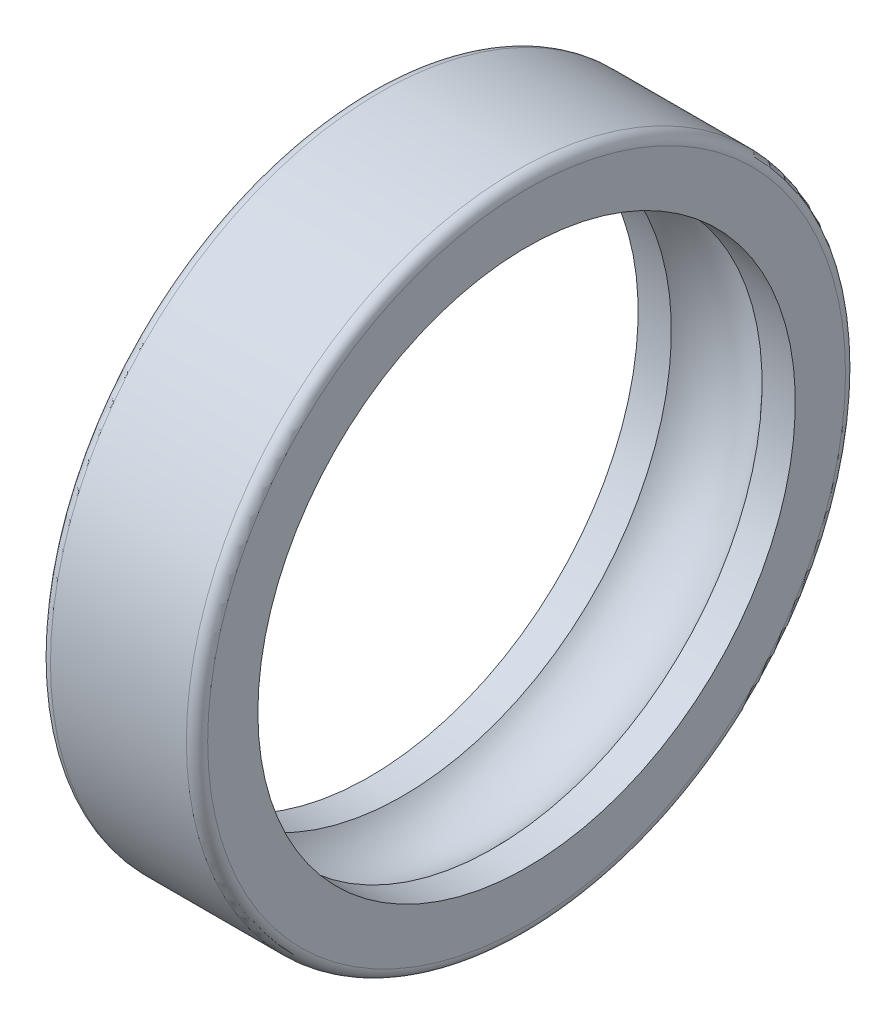
from build123d import *

# Parameters (mm, degrees)
FILLET1_R = 2.1


with BuildPart() as part:
    # Sketch1 → Revolve1 (revolve)
    with BuildSketch(Plane.XY):
        with BuildLine():
            Line((8.94427191, 53), (15.5, 53))
            Line((15.5, 53), (15.5, 65))
            Line((15.5, 65), (-15.5, 65))
            Line((-15.5, 65), (-15.5, 53))
            Line((-15.5, 53), (-8.94427191, 53))
            ThreePointArc((-8.94427191, 53), (0, 57), (8.94427191, 53))
        make_face()
    revolve(axis=Axis((-15.5, 0, 0), (1, 0, 0)))

    # Fillet1
    fillet1_edges = [part.edges().sort_by_distance(p)[0] for p in [
        (15.5, -65, 0),
        (-15.5, -65, 0),
    ]]
    fillet(fillet1_edges, radius=FILLET1_R)


solid = part.part
